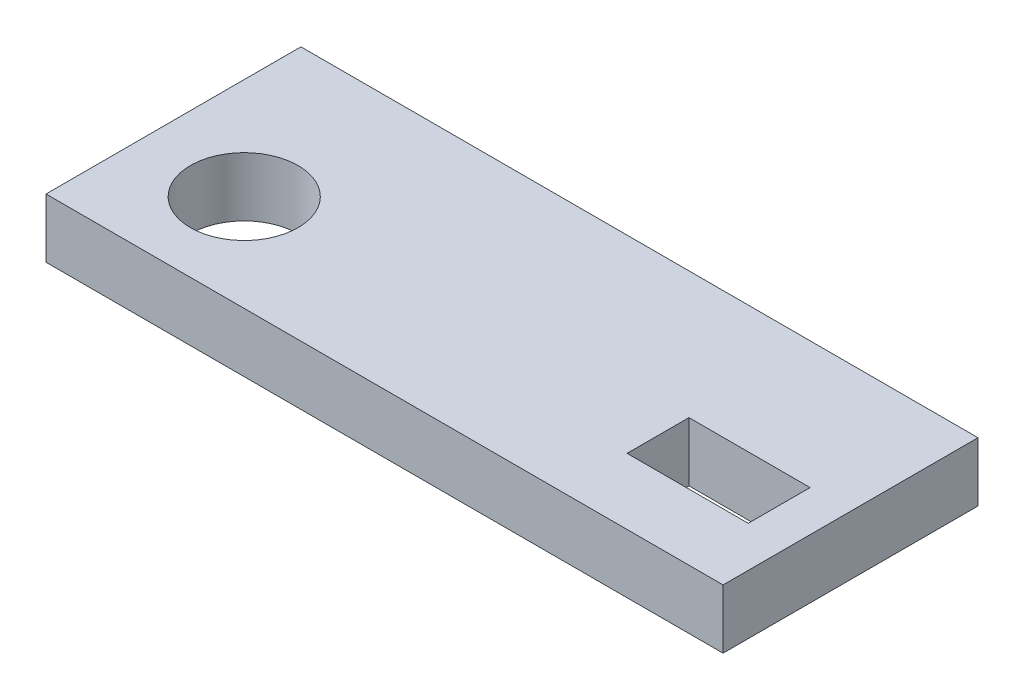
from build123d import *

# Parameters (mm, degrees)
SKETCH1_W           = 66.4
SKETCH1_H           = 5.8
BOSS_EXTRUDE1_DEPTH = 25
SKETCH3_R           = 5.28
SKETCH3_W           = 11.88
SKETCH3_H           = 6.07
CUT_EXTRUDE3_DEPTH  = 6.8


with BuildPart() as part:
    # Sketch1 → Boss-Extrude1 (new body)
    with BuildSketch(Plane.XY):
        with Locations((0, -59.6)):
            Rectangle(SKETCH1_W, SKETCH1_H)
    extrude(amount=BOSS_EXTRUDE1_DEPTH)

    # Sketch3 → Cut-Extrude3 (cut, through all)
    with BuildSketch(Plane(origin=(0, -56.7, 0), x_dir=(1, 0, 0), z_dir=(0, 1, 0))):
        with Locations((-23.26, -15.500000019)):
            Circle(SKETCH3_R)
        with Locations((23.26, -15.500000019)):
            Rectangle(SKETCH3_W, SKETCH3_H)
    extrude(amount=-CUT_EXTRUDE3_DEPTH, mode=Mode.SUBTRACT)


solid = part.part
